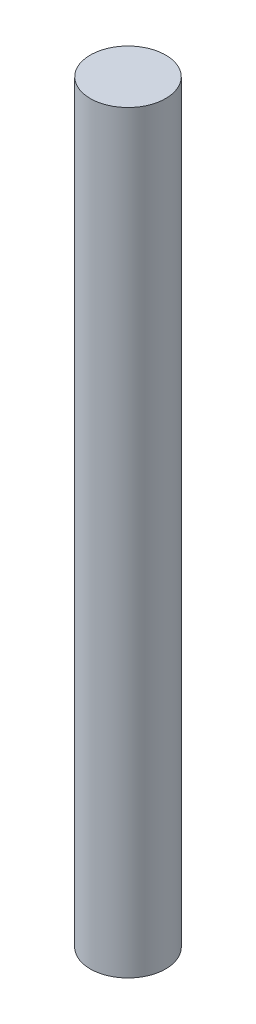
from build123d import *

# Parameters (mm, degrees)
SKETCH1_R           = 1.5
BOSS_EXTRUDE1_DEPTH = 30


with BuildPart() as part:
    # Sketch1 → Boss-Extrude1 (new body)
    with BuildSketch(Plane(origin=(0, 0, 0), x_dir=(1, 0, 0), z_dir=(0, 1, 0))):
        Circle(SKETCH1_R)
    extrude(amount=BOSS_EXTRUDE1_DEPTH)


solid = part.part
